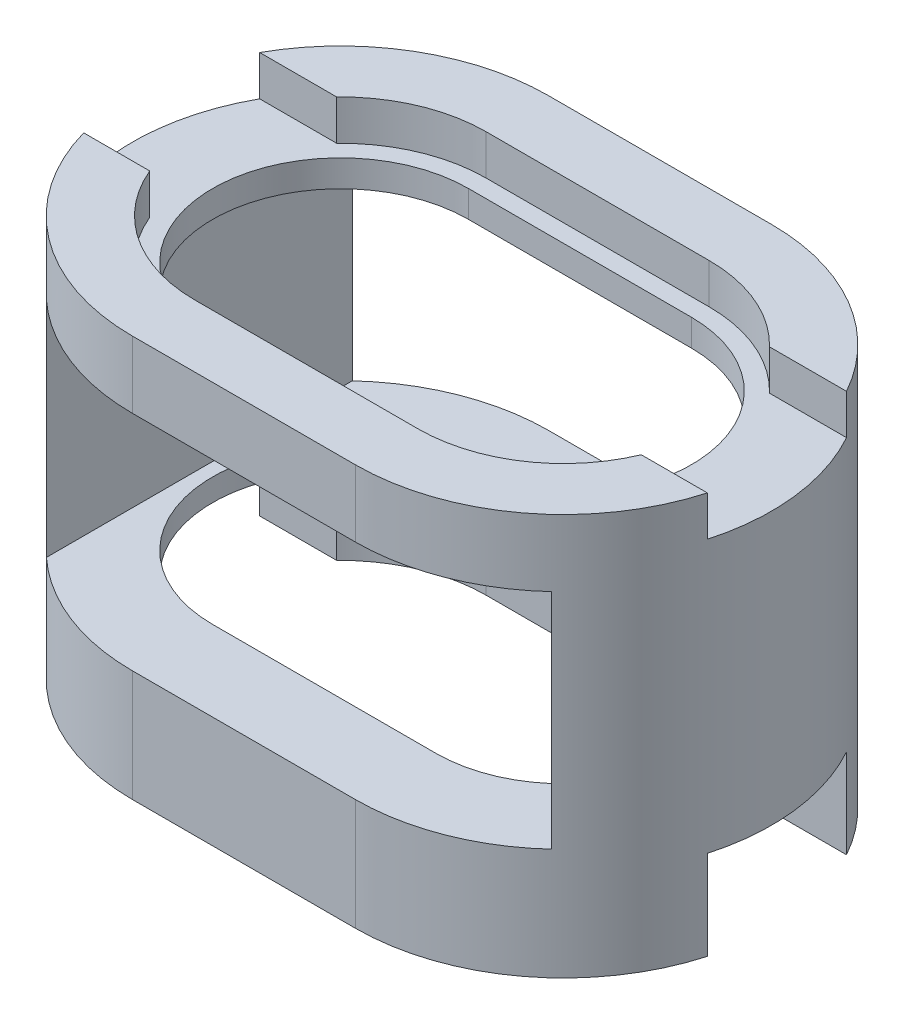
from build123d import *

# Parameters (mm, degrees)
BOSS_EXTRUDE1_DEPTH = 9
BOSS_EXTRUDE2_DEPTH = 6.1
SKETCH3_W           = 11.33
SKETCH3_H           = 5
CUT_EXTRUDE1_DEPTH  = 10
SKETCH4_W           = 15
SKETCH4_H           = 3.533
CUT_EXTRUDE2_DEPTH  = 0.9
SKETCH5_W           = 15
SKETCH5_H           = 3.533
CUT_EXTRUDE3_DEPTH  = 2


with BuildPart() as part:
    # Sketch1 → Boss-Extrude1 (new body)
    with BuildSketch(Plane(origin=(0, 0, 0), x_dir=(1, 0, 0), z_dir=(0, 1, 0))):
        with BuildLine():
            Line((0, 4.6665), (5, 4.6665))
            ThreePointArc((5, 4.6665), (9.6665, 0), (5, -4.6665))
            Line((5, -4.6665), (0, -4.6665))
            ThreePointArc((0, -4.6665), (-4.6665, 0), (0, 4.6665))
        make_face()
        with BuildLine():
            Line((0, 3.2665), (5, 3.2665))
            ThreePointArc((5, 3.2665), (8.2665, 0), (5, -3.2665))
            Line((5, -3.2665), (0, -3.2665))
            ThreePointArc((0, -3.2665), (-3.2665, 0), (0, 3.2665))
        make_face(mode=Mode.SUBTRACT)
    extrude(amount=BOSS_EXTRUDE1_DEPTH)

    # Sketch2 → Boss-Extrude2 (add)
    with BuildSketch(Plane(origin=(0, 2, 0), x_dir=(1, 0, 0), z_dir=(0, 1, 0))):
        with BuildLine():
            Line((0, 3.2665), (5, 3.2665))
            ThreePointArc((5, 3.2665), (8.2665, 0), (5, -3.2665))
            Line((5, -3.2665), (0, -3.2665))
            ThreePointArc((0, -3.2665), (-3.2665, 0), (0, 3.2665))
        make_face()
        with BuildLine():
            Line((0, 2.8665), (5, 2.8665))
            ThreePointArc((5, 2.8665), (7.8665, 0), (5, -2.8665))
            Line((5, -2.8665), (0, -2.8665))
            ThreePointArc((0, -2.8665), (-2.8665, 0), (0, 2.8665))
        make_face(mode=Mode.SUBTRACT)
    extrude(amount=BOSS_EXTRUDE2_DEPTH)

    # Sketch3 → Cut-Extrude1 (cut)
    with BuildSketch(Plane.XY.offset(4.6665)):
        with Locations((2.5, 5)):
            Rectangle(SKETCH3_W, SKETCH3_H)
    extrude(amount=-CUT_EXTRUDE1_DEPTH, mode=Mode.SUBTRACT)

    # Sketch4 → Cut-Extrude2 (cut)
    with BuildSketch(Plane(origin=(0, 9, 0), x_dir=(1, 0, 0), z_dir=(0, 1, 0))):
        with Locations((2.5, 0.5)):
            Rectangle(SKETCH4_W, SKETCH4_H)
    extrude(amount=-CUT_EXTRUDE2_DEPTH, mode=Mode.SUBTRACT)

    # Sketch5 → Cut-Extrude3 (cut)
    with BuildSketch(Plane.XZ):
        with Locations((2.5, -0.5)):
            Rectangle(SKETCH5_W, SKETCH5_H)
    extrude(amount=-CUT_EXTRUDE3_DEPTH, mode=Mode.SUBTRACT)


solid = part.part
